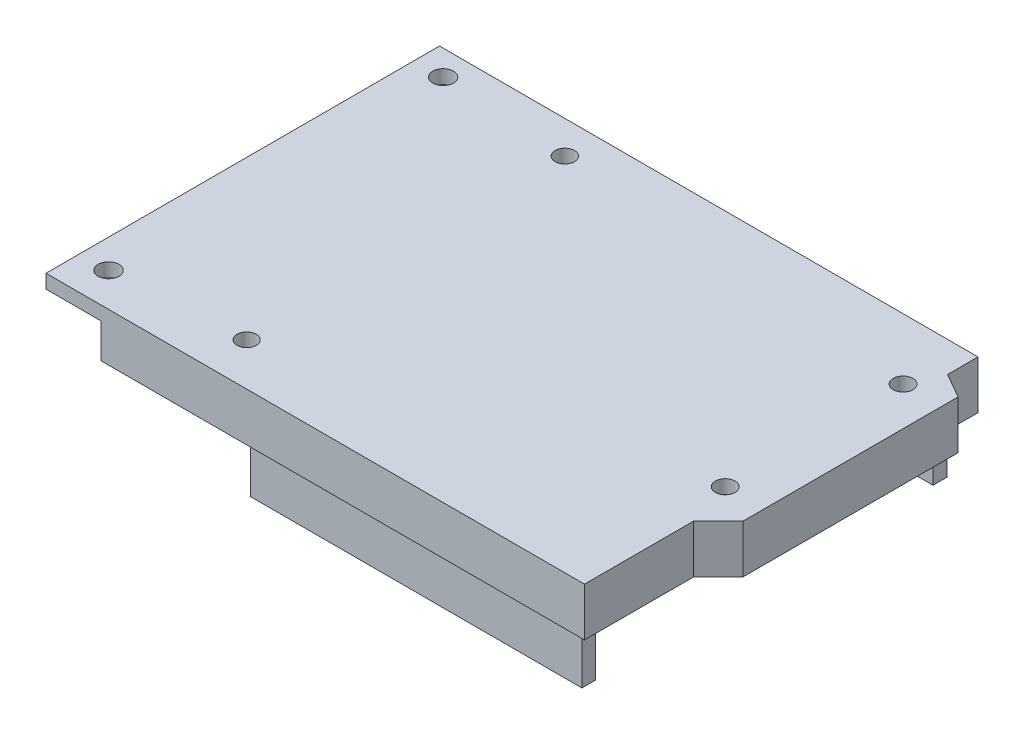
from build123d import *

# Parameters (mm, degrees)
EXTRUDE_1_DEPTH     = 7
SKETCH_2_R          = 1.499068593
SKETCH_2_R_2        = 1.507712359
CUT_EXTRUDE_1_DEPTH = 2
SKETCH_3_R          = 1.404162934
SKETCH_3_R_2        = 1.394662516
SKETCH_3_R_3        = 1.426202715
SKETCH_3_R_4        = 1.43
CUT_EXTRUDE_2_DEPTH = 2
SKETCH_5_W          = 8
SKETCH_5_H          = 5
CUT_EXTRUDE_3_DEPTH = 135
SKETCH_6_W          = 48
SKETCH_6_H          = 2
SKETCH_6_W_2        = 38.5
EXTRUDE_2_DEPTH     = 8.5
SKETCH_7_W          = 16
SKETCH_7_H          = 11.5
EXTRUDE_3_DEPTH     = 10
SKETCH_9_W          = 2
SKETCH_9_H          = 8.5
CUT_EXTRUDE_4_DEPTH = 10
SKETCH_10_W         = 9
SKETCH_10_H         = 11
EXTRUDE_4_DEPTH     = 3
EXTRUDE_5_DEPTH     = 10.5
SKETCH_12_R         = 1.404162934
SKETCH_12_R_2       = 1.394662516
SKETCH_12_R_3       = 1.451975752
SKETCH_12_R_4       = 1.426202713
CUT_EXTRUDE_5_DEPTH = 10.5


with BuildPart() as part:
    # 草图1 → 凸台-拉伸1 (new body)
    with BuildSketch(Plane(origin=(0, 0, 0), x_dir=(1, 0, 0), z_dir=(0, 1, 0))):
        Polygon((0, 15.813216669), (3.578877576, 19.392094245), (3.578877576, 50.54921212), (0, 52.598301515), (0, 57), (-78, 57), (-78, 0), (0, 0), align=None)
    extrude(amount=EXTRUDE_1_DEPTH)

    # 草图2 → 切除-拉伸1 (cut)
    with BuildSketch(Plane(origin=(0, 7, 0), x_dir=(1, 0, 0), z_dir=(0, 1, 0))):
        with Locations((-73.839384245, 53.362286428)):
            Circle(SKETCH_2_R)
        with Locations((-73.839384245, 4.894512841)):
            Circle(SKETCH_2_R_2)
    extrude(amount=-CUT_EXTRUDE_1_DEPTH, mode=Mode.SUBTRACT)

    # 草图3 → 切除-拉伸2 (cut)
    with BuildSketch(Plane(origin=(0, 7, 0), x_dir=(1, 0, 0), z_dir=(0, 1, 0))):
        with Locations((-55.116977268, 52.270174236)):
            Circle(SKETCH_3_R)
        with Locations((-55.116977268, 6.180833795)):
            Circle(SKETCH_3_R_2)
        with Locations((-2.023984121, 48.167273678)):
            Circle(SKETCH_3_R_3)
        with Locations((-2.023984121, 22.405667973)):
            Circle(SKETCH_3_R_4)
    extrude(amount=-CUT_EXTRUDE_2_DEPTH, mode=Mode.SUBTRACT)

    # 草图5 → 切除-拉伸3 (cut)
    with BuildSketch(Plane.XY):
        with Locations((-74, 2.5)):
            Rectangle(SKETCH_5_W, SKETCH_5_H)
    extrude(amount=-CUT_EXTRUDE_3_DEPTH, mode=Mode.SUBTRACT)

    # 草图6 → 凸台-拉伸2 (add)
    with BuildSketch(Plane(origin=(0, 0, 0), x_dir=(-1, 0, 0), z_dir=(0, -1, 0))):
        with Locations((26.66066087, 3.286523813)):
            Rectangle(SKETCH_6_W, SKETCH_6_H)
        with Locations((21.91066087, 54.141974349)):
            Rectangle(SKETCH_6_W_2, SKETCH_6_H)
    extrude(amount=EXTRUDE_2_DEPTH)

    # 草图7 → 凸台-拉伸3 (add)
    with BuildSketch(Plane(origin=(0, 0, 0), x_dir=(-1, 0, 0), z_dir=(0, -1, 0))):
        with Locations((67.251369974, 18.045913209)):
            Rectangle(SKETCH_7_W, SKETCH_7_H)
    extrude(amount=EXTRUDE_3_DEPTH)

    # 草图9 → 切除-拉伸4 (cut)
    with BuildSketch(Plane.ZY.offset(41.16066087)):
        with Locations((-54.141974349, -4.25)):
            Rectangle(SKETCH_9_W, SKETCH_9_H)
    extrude(amount=-CUT_EXTRUDE_4_DEPTH, mode=Mode.SUBTRACT)



with BuildPart() as body_2:
    # 草图10 → 凸台-拉伸4 (new body)
    with BuildSketch(Plane.ZY.offset(70)):
        with Locations((-49.837173762, -5.5)):
            Rectangle(SKETCH_10_W, SKETCH_10_H)
    extrude(amount=-EXTRUDE_4_DEPTH)


with BuildPart() as part_1:
    add(part.part)

    add(body_2.part)  # 凸台-拉伸5 merges body 2
    # 草图11 → 凸台-拉伸5 (add)
    with BuildSketch(Plane(origin=(-67, 0, 0), x_dir=(0, 0, -1), z_dir=(1, 0, 0))):
        with BuildLine():
            Line((45.337173762, 0), (54.337173762, 0))
            Line((54.337173762, 0), (54.337173762, -6.5))
            ThreePointArc((54.337173762, -6.5), (49.837173762, -11), (45.337173762, -6.5))
            Line((45.337173762, -6.5), (45.337173762, 0))
        make_face()
    extrude(amount=EXTRUDE_5_DEPTH)

    # 草图12 → 切除-拉伸5 (cut)
    with BuildSketch(Plane(origin=(0, 5, 0), x_dir=(1, 0, 0), z_dir=(0, 1, 0))):
        with Locations((-55.116977268, 52.270174236)):
            Circle(SKETCH_12_R)
        with Locations((-55.116977268, 6.180833795)):
            Circle(SKETCH_12_R_2)
        with Locations((-2.040608488, 22.420040311)):
            Circle(SKETCH_12_R_3)
        with Locations((-2.023984121, 48.167273678)):
            Circle(SKETCH_12_R_4)
    extrude(amount=-CUT_EXTRUDE_5_DEPTH, mode=Mode.SUBTRACT)


solid = part_1.part
